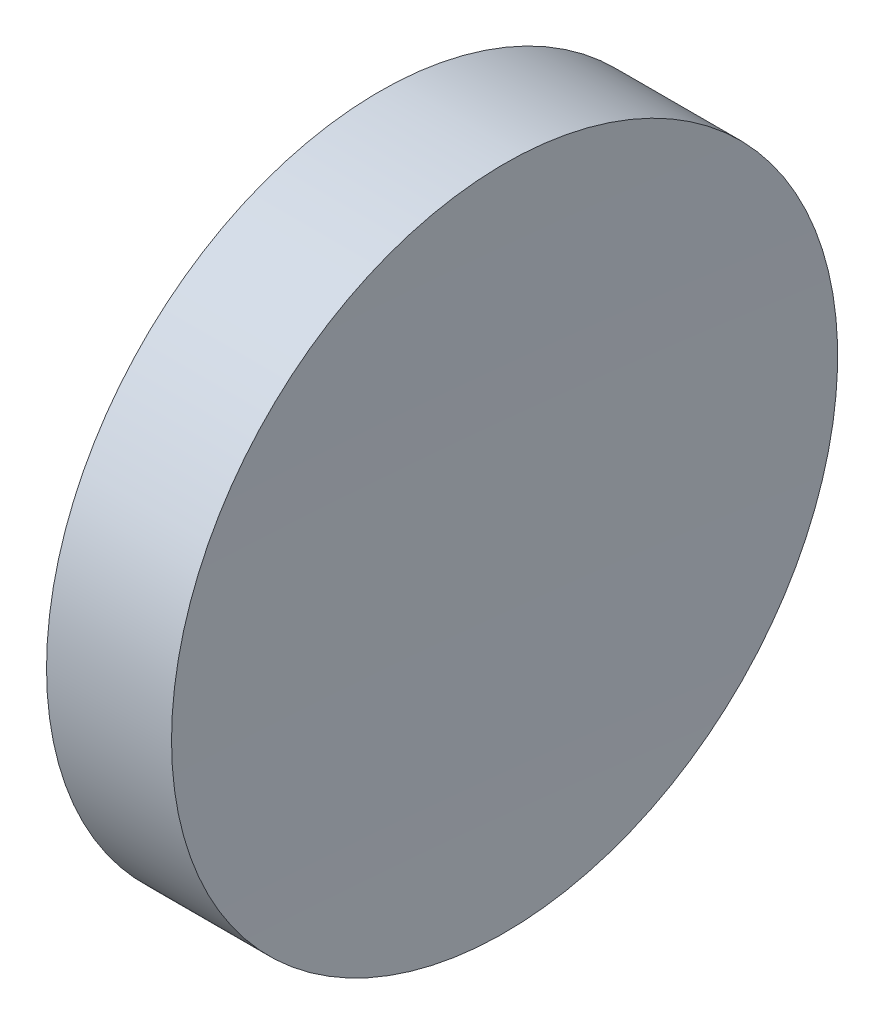
from build123d import *


with BuildPart() as part:
    # 草图1 → 旋转1 (revolve)
    with BuildSketch(Plane(origin=(0, 0, 0), x_dir=(1, 0, 0), z_dir=(0, 1, 0)), mode=Mode.PRIVATE) as revolve_1_sk:
        with BuildLine():
            Line((0, 0), (9.21, 0))
            ThreePointArc((9.21, 0), (9.290661265, 12.701024481), (9.532632046, 25.4))
            Line((9.532632046, 25.4), (0, 25.4))
            Line((0, 25.4), (0, 0))
        make_face()
    revolve(revolve_1_sk.sketch.rotate(Axis((0, 0, 0), (1, 0, 0)), 180), axis=Axis((0, 0, 0), (1, 0, 0)))  # turned: the seam where the file's is


solid = part.part
